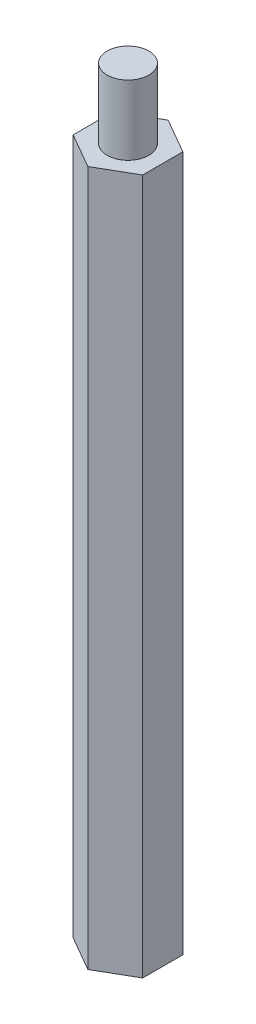
from build123d import *

# Parameters (mm, degrees)
BOSS_EXTRUDE1_DEPTH = 100
SKETCH2_R           = 3
BOSS_EXTRUDE2_DEPTH = 10
SKETCH3_R           = 3
CUT_EXTRUDE1_DEPTH  = 12


with BuildPart() as part:
    # Sketch1 → Boss-Extrude1 (new body)
    with BuildSketch(Plane(origin=(0, 0, 0), x_dir=(1, 0, 0), z_dir=(0, 1, 0))):
        Polygon((0, -5.773502692), (5, -2.886751346), (5, 2.886751346), (0, 5.773502692), (-5, 2.886751346), (-5, -2.886751346), align=None)
    extrude(amount=BOSS_EXTRUDE1_DEPTH)

    # Sketch2 → Boss-Extrude2 (add)
    with BuildSketch(Plane(origin=(0, 100, 0), x_dir=(1, 0, 0), z_dir=(0, 1, 0))):
        Circle(SKETCH2_R)
    extrude(amount=BOSS_EXTRUDE2_DEPTH)

    # Sketch3 → Cut-Extrude1 (cut)
    with BuildSketch(Plane.XZ):
        Circle(SKETCH3_R)
    extrude(amount=-CUT_EXTRUDE1_DEPTH, mode=Mode.SUBTRACT)


solid = part.part
